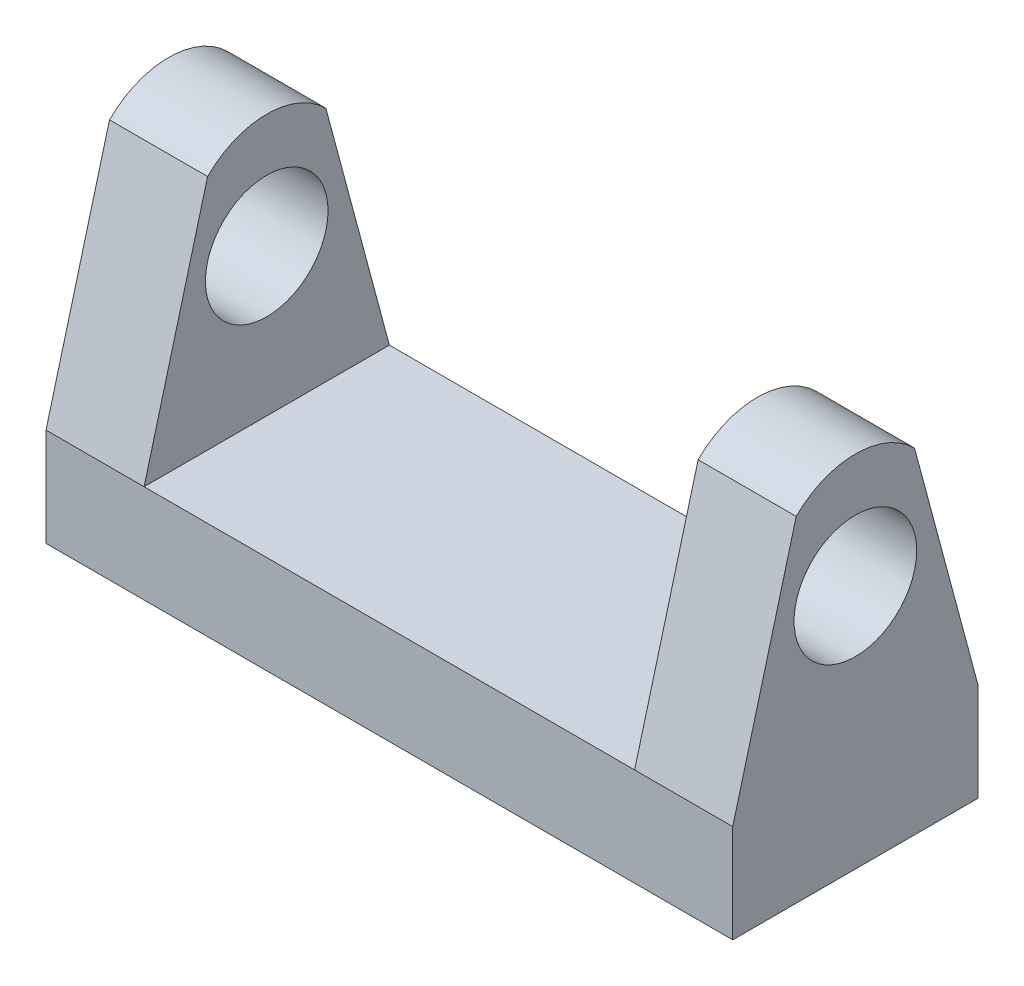
from build123d import *

# Parameters (mm, degrees)
SKETCH1_W           = 35.56
SKETCH1_H           = 12.7
BOSS_EXTRUDE1_DEPTH = 5.08
BOSS_EXTRUDE2_DEPTH = 5.08
SKETCH3_R           = 3.175
CUT_EXTRUDE1_DEPTH  = 36.56


with BuildPart() as part:
    # Sketch1 → Boss-Extrude1 (new body)
    with BuildSketch(Plane(origin=(0, 0, 0), x_dir=(1, 0, 0), z_dir=(0, 1, 0))):
        Rectangle(SKETCH1_W, SKETCH1_H)
    extrude(amount=BOSS_EXTRUDE1_DEPTH)

    # Sketch2 → Boss-Extrude2 (add)
    with BuildSketch(Plane(origin=(17.78, 0, 0), x_dir=(0, 0, -1), z_dir=(1, 0, 0))):
        with BuildLine():
            Line((-6.35, 5.08), (-3.062998127, 17.347257994))
            ThreePointArc((-3.062998127, 17.347257994), (0, 18.61599336), (3.062998127, 17.347257994))
            Line((3.062998127, 17.347257994), (6.35, 5.08))
            Line((6.35, 5.08), (-6.35, 5.08))
        make_face()
    boss_extrude2 = extrude(amount=-BOSS_EXTRUDE2_DEPTH)

    # Mirror1: Boss-Extrude2 across plane
    add(boss_extrude2.mirror(Plane(origin=(0, 0, 0), x_dir=(0, 0, 1), z_dir=(1, 0, 0))))

    # Sketch3 → Cut-Extrude1 (cut, through all)
    with BuildSketch(Plane(origin=(17.78, 0, 0), x_dir=(0, 0, -1), z_dir=(1, 0, 0))):
        with Locations((0, 12.7)):
            Circle(SKETCH3_R)
    extrude(amount=-CUT_EXTRUDE1_DEPTH, mode=Mode.SUBTRACT)


solid = part.part
